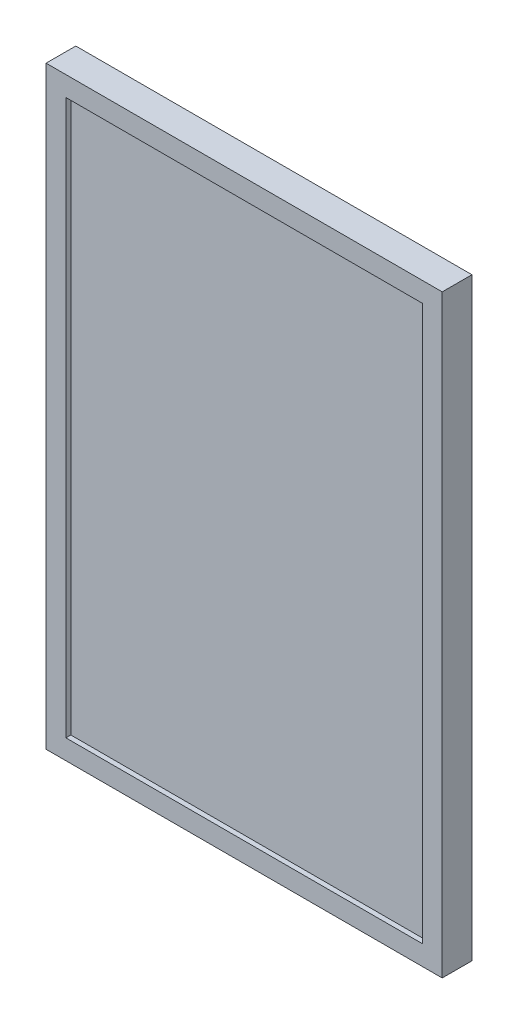
from build123d import *

# Parameters (mm, degrees)
SKETCH4_W           = 101.6
SKETCH4_H           = 152.4
BOSS_EXTRUDE3_DEPTH = 7.62
SKETCH5_W           = 91.44
SKETCH5_H           = 142.24
CUT_EXTRUDE1_DEPTH  = 1.27


with BuildPart() as part:
    # Sketch4 → Boss-Extrude3 (new body)
    with BuildSketch(Plane.XY):
        with Locations((0.567597765, -19.156424581)):
            Rectangle(SKETCH4_W, SKETCH4_H)
    extrude(amount=BOSS_EXTRUDE3_DEPTH)

    # Sketch5 → Cut-Extrude1 (cut)
    with BuildSketch(Plane.XY.offset(7.62)):
        with Locations((0.567597765, -19.156424581)):
            Rectangle(SKETCH5_W, SKETCH5_H)
    extrude(amount=-CUT_EXTRUDE1_DEPTH, mode=Mode.SUBTRACT)


solid = part.part
